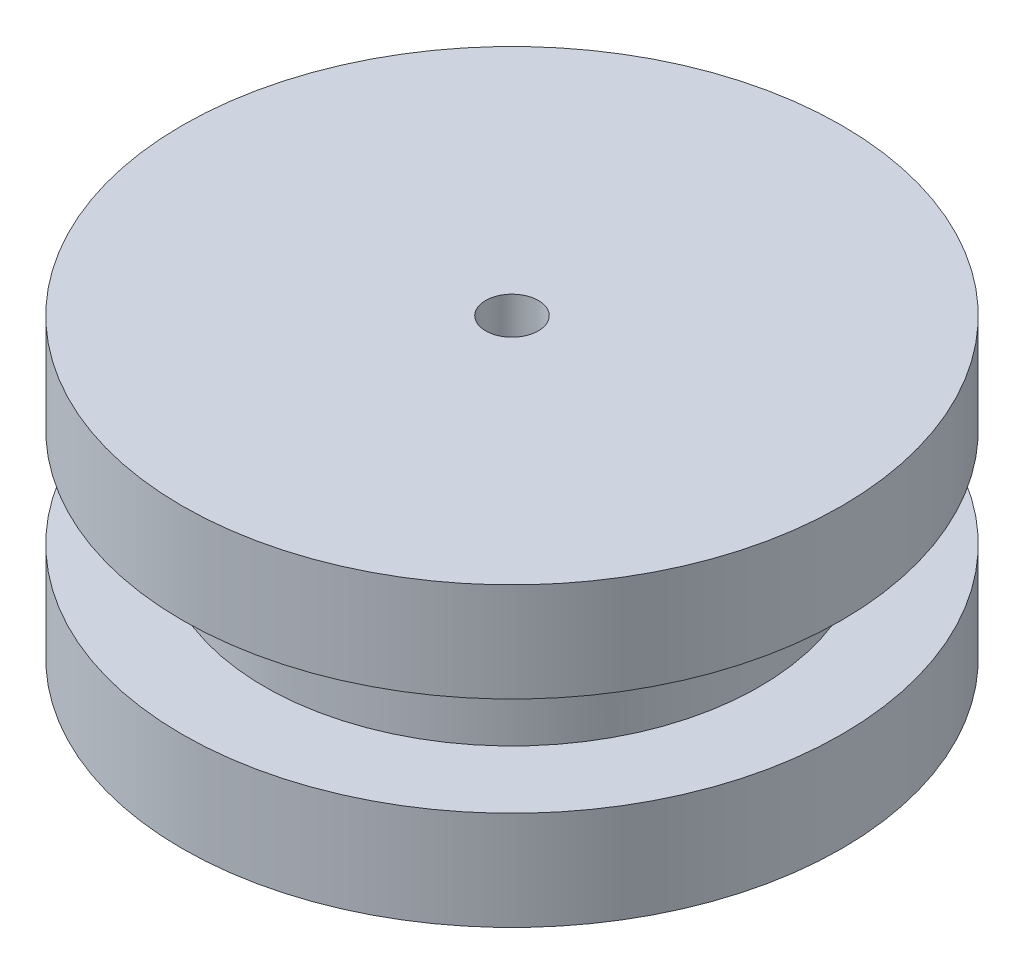
from build123d import *

# Parameters (mm, degrees)
SKETCH1_R            = 11.25
BOSS_EXTRUDE1_DEPTH  = 4.5
SKETCH2_R            = 15
BOSS_EXTRUDE2_DEPTH  = 4.5
SKETCH3_R            = 15
BOSS_EXTRUDE3_DEPTH  = 4.5
M2_CLEARANCE_HOLE1_D = 2.4


with BuildPart() as part:
    # Sketch1 → Boss-Extrude1 (new body)
    with BuildSketch(Plane(origin=(0, 0, 0), x_dir=(1, 0, 0), z_dir=(0, 1, 0))):
        Circle(SKETCH1_R)
    extrude(amount=BOSS_EXTRUDE1_DEPTH)

    # Sketch2 → Boss-Extrude2 (add)
    with BuildSketch(Plane(origin=(0, 4.5, 0), x_dir=(1, 0, 0), z_dir=(0, 1, 0))):
        Circle(SKETCH2_R)
    extrude(amount=BOSS_EXTRUDE2_DEPTH)

    # Sketch3 → Boss-Extrude3 (add)
    with BuildSketch(Plane(origin=(0, 0, 0), x_dir=(-1, 0, 0), z_dir=(0, -1, 0))):
        Circle(SKETCH3_R)
    extrude(amount=BOSS_EXTRUDE3_DEPTH)

    # M2 Clearance Hole1 (through all)
    with Locations(Plane(origin=(0, -4.5, 0), x_dir=(-1, 0, 0), z_dir=(0, -1, 0))):
        with Locations((0, 0)):
            Hole(M2_CLEARANCE_HOLE1_D / 2)


solid = part.part
